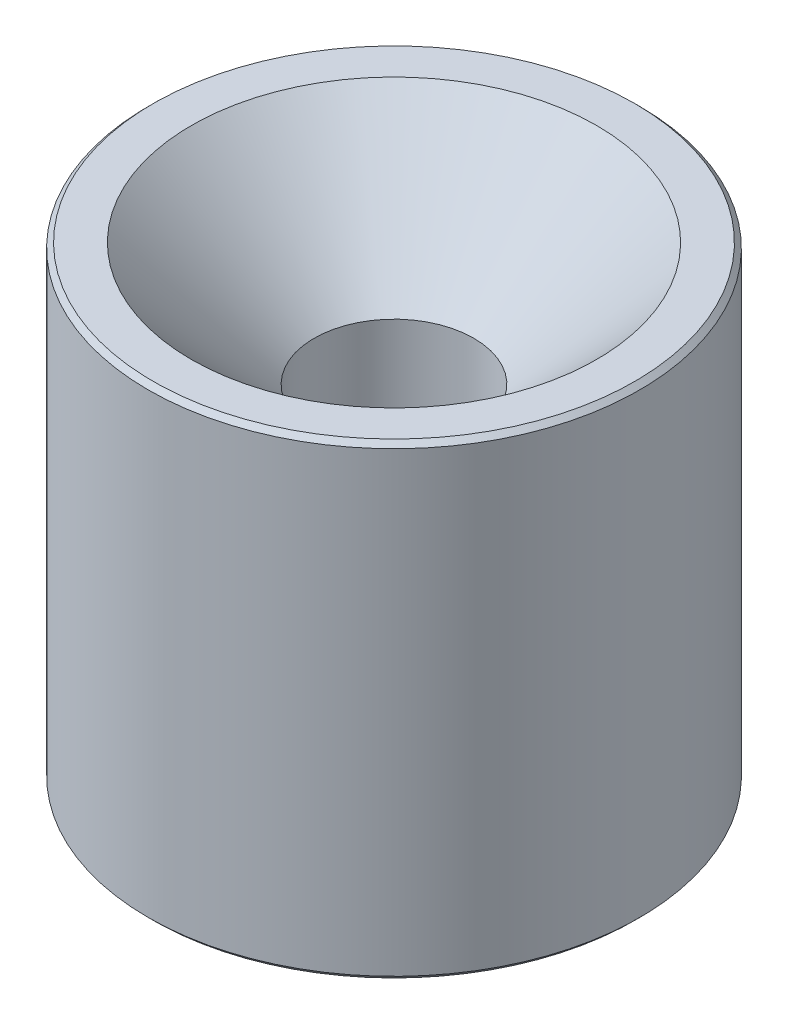
from build123d import *


with BuildPart() as part:
    # Sketch1 → Revolve1 (revolve)
    with BuildSketch(Plane.XY):
        Polygon((3.45, -9.5), (9.8, -9.5), (10, -9.3), (10, 9.3), (9.8, 9.5), (8.25, 9.5), (3.25, 4.5), (3.25, -9.3), align=None)
    revolve(axis=Axis((0, 9.5, 0), (0, -1, 0)))


solid = part.part
